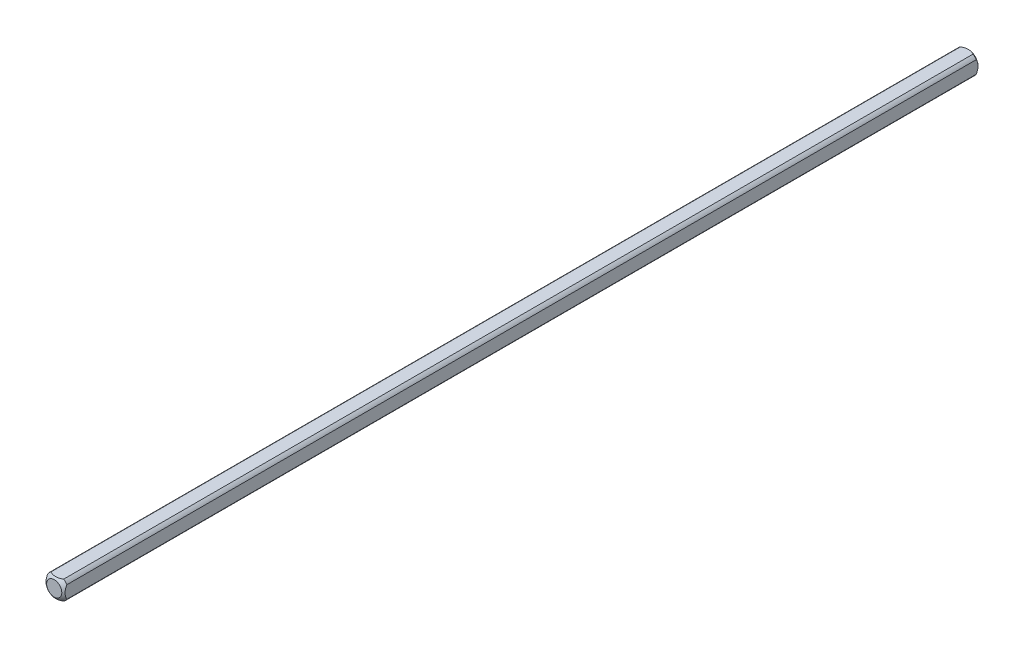
from build123d import *

# Parameters (mm, degrees)
SKETCH1_W           = 6.35
SKETCH1_H           = 6.35
BOSS_EXTRUDE1_DEPTH = 152.4
SKETCH2_OUTSIDE_W   = 38.882
SKETCH2_OUTSIDE_H   = 38.882
SKETCH2_OUTSIDE_R   = 3.81
CUT_EXTRUDE1_DEPTH  = 153.4


with BuildPart() as part:
    # Sketch1 → Boss-Extrude1 (new body)
    with BuildSketch(Plane.XY):
        Rectangle(SKETCH1_W, SKETCH1_H)
    extrude(amount=BOSS_EXTRUDE1_DEPTH)

    # Sketch2 outside → Cut-Extrude1 (cut, through all)
    with BuildSketch(Plane(origin=(0, 0, 0), x_dir=(-1, 0, 0), z_dir=(0, 0, -1))):
        Rectangle(SKETCH2_OUTSIDE_W, SKETCH2_OUTSIDE_H)
        Circle(SKETCH2_OUTSIDE_R, mode=Mode.SUBTRACT)
    extrude(amount=-CUT_EXTRUDE1_DEPTH, mode=Mode.SUBTRACT)

    # Sketch3 → Cut-Revolve1 (revolve, cut)
    with BuildSketch(Plane(origin=(0, 0, 0), x_dir=(1, 0, 0), z_dir=(0, 1, 0))):
        with BuildLine():
            Line((-5.053685963, -3.893335876), (-5.053685963, 5.740530545))
            Line((-5.053685963, 5.740530545), (0, 5.740530545))
            Line((0, 5.740530545), (0, 0.670274551))
            ThreePointArc((0, 0.670274551), (-3.404639553, -0.639469554), (-5.053685963, -3.893335876))
        make_face()
    revolve(axis=Axis((0, 0, 152.4), (0, 0, -1)), mode=Mode.SUBTRACT)

    # Mirror1: part across plane


with BuildPart() as part_1:
    add(part.part)
    add(part.part.mirror(Plane(origin=(0, 0, 152.4), x_dir=(1, 0, 0), z_dir=(0, 0, -1))))


solid = part_1.part
